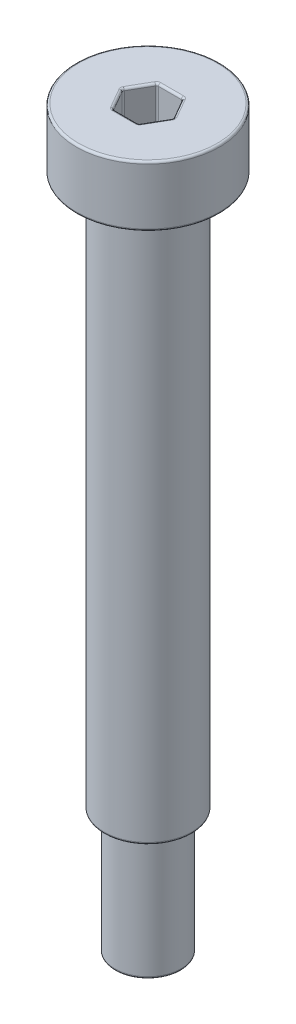
from build123d import *

# Parameters (mm, degrees)
SKETCH_1_R          = 3.99
EXTRUDE_1_DEPTH     = 25
SKETCH_2_R          = 6.5
EXTRUDE_2_DEPTH     = 5.5
CUT_EXTRUDE_1_DEPTH = 3.3
SKETCH_4_R          = 3
EXTRUDE_3_DEPTH     = 11.25
FILLET_1_R          = 0.2


with BuildPart() as part:
    # 草图1 → 凸台-拉伸1 (new body, symmetric)
    with BuildSketch(Plane(origin=(0, 0, 0), x_dir=(1, 0, 0), z_dir=(0, 1, 0))):
        Circle(SKETCH_1_R)
    extrude(amount=EXTRUDE_1_DEPTH, both=True)

    # 草图2 → 凸台-拉伸2 (add)
    with BuildSketch(Plane(origin=(0, 25, 0), x_dir=(1, 0, 0), z_dir=(0, 1, 0))):
        Circle(SKETCH_2_R)
    extrude(amount=EXTRUDE_2_DEPTH)

    # 草图3 → 切除-拉伸1 (cut)
    with BuildSketch(Plane(origin=(0, 30.5, 0), x_dir=(1, 0, 0), z_dir=(0, 1, 0))):
        Polygon((2.309401077, 0), (1.154700538, 2), (-1.154700538, 2), (-2.309401077, 0), (-1.154700538, -2), (1.154700538, -2), align=None)
    extrude(amount=-CUT_EXTRUDE_1_DEPTH, mode=Mode.SUBTRACT)

    # 草图4 → 凸台-拉伸3 (add)
    with BuildSketch(Plane.XZ.offset(25)):
        Circle(SKETCH_4_R)
    extrude(amount=EXTRUDE_3_DEPTH)

    # 圆角1
    fillet_1_edges = [part.edges().sort_by_distance(p)[0] for p in [
        (1.732050808, 27.2, 1),
        (2.309401077, 28.85, 0),
        (0, 27.2, 2),
        (1.154700538, 28.85, 2),
        (-1.732050808, 27.2, 1),
        (-1.154700538, 28.85, 2),
        (-1.732050808, 27.2, -1),
        (-2.309401077, 28.85, 0),
        (0, 27.2, -2),
        (-1.154700538, 28.85, -2),
        (1.732050808, 27.2, -1),
        (1.154700538, 28.85, -2),
        (1.732050808, 30.5, 1),
        (1.732050808, 30.5, -1),
        (0, 30.5, -2),
        (-1.732050808, 30.5, -1),
        (-1.732050808, 30.5, 1),
        (0, 30.5, 2),
        (-3, -25, 0),
        (-3, -36.25, 0),
        (-3.99, -25, 0),
        (-6.5, 25, 0),
        (-6.5, 30.5, 0),
    ]]
    fillet(fillet_1_edges, radius=FILLET_1_R)


solid = part.part
